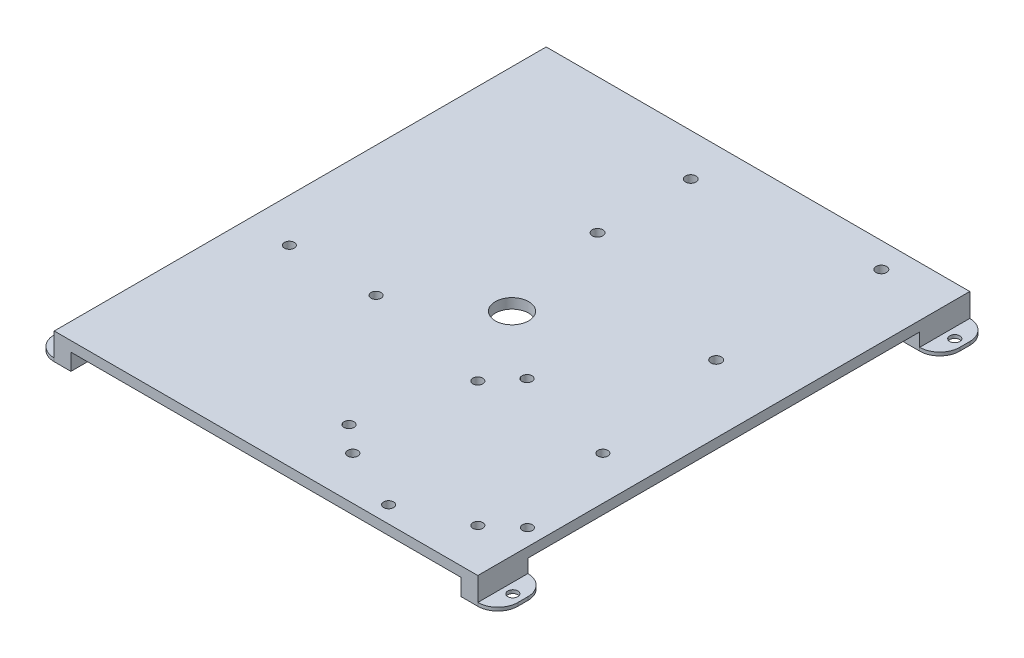
from build123d import *

# Parameters (mm, degrees)
BASE_SKETCH_W              = 127
BASE_SKETCH_H              = 147.5
BASE_SKETCH_R              = 5
BASE_DEPTH                 = 3
LEGS_SKETCH_W              = 5
LEGS_SKETCH_H              = 15
LEGS_DEPTH                 = 5
MOUNT_SKETCH_W             = 15
MOUNT_SKETCH_H             = 1
MOUNT_DEPTH                = 6
DONT_CUT_URSELF_R          = 6
MOUNTING_HOLE_SKETCH_R     = 1.5
MOUNTING_HOLE_1_DEPTH      = 2
MOUNTING_HOLE_2_SKETCH_R   = 1.5
MOUNTING_HOLE_2_DEPTH      = 2
MOUNT_2_SKETCH_W           = 15
MOUNT_2_SKETCH_H           = 1
MOUNT_2_DEPTH              = 6
DONT_CUT_URSELF_2_R        = 6
MOUNTING_HOLE_3_SKETCH_R   = 1.5
MOUNTING_HOLE_3_DEPTH      = 2
MOUNTING_HOLE_4_SKETCH_R   = 1.5
MOUNTING_HOLE_4_DEPTH      = 2
HOLES_FOR_PARTS_REACH      = 10
HOLES_FOR_PARTS_SKETCH_R   = 1.5
HOLES_FOR_PARTS_SKETCH_R_2 = 1.59


with BuildPart() as part:
    # Base Sketch → Base (new body)
    with BuildSketch(Plane(origin=(0, 0, 0), x_dir=(1, 0, 0), z_dir=(0, 1, 0))):
        Rectangle(BASE_SKETCH_W, BASE_SKETCH_H)
        Circle(BASE_SKETCH_R, mode=Mode.SUBTRACT)
    extrude(amount=BASE_DEPTH)

    # Legs Sketch → Legs (add)
    with BuildSketch(Plane.XZ):
        with Locations((-61, -66.25)):
            Rectangle(LEGS_SKETCH_W, LEGS_SKETCH_H)
        with Locations((61, -66.25)):
            Rectangle(LEGS_SKETCH_W, LEGS_SKETCH_H)
        with Locations((-61, 66.25)):
            Rectangle(LEGS_SKETCH_W, LEGS_SKETCH_H)
        with Locations((61, 66.25)):
            Rectangle(LEGS_SKETCH_W, LEGS_SKETCH_H)
    extrude(amount=LEGS_DEPTH)

    # Mount Sketch → Mount (add)
    with BuildSketch(Plane(origin=(63.5, 0, 0), x_dir=(0, 0, -1), z_dir=(1, 0, 0))):
        with Locations((-66.25, -4.5)):
            Rectangle(MOUNT_SKETCH_W, MOUNT_SKETCH_H)
        with Locations((66.25, -4.5)):
            Rectangle(MOUNT_SKETCH_W, MOUNT_SKETCH_H)
    extrude(amount=MOUNT_DEPTH)

    # Dont cut urself
    dont_cut_urself_edges = [part.edges().sort_by_distance(p)[0] for p in [
        (69.5, -4.5, 58.75),
        (69.5, -4.5, 73.75),
        (69.5, -4.5, -73.75),
        (69.5, -4.5, -58.75),
    ]]
    fillet(dont_cut_urself_edges, radius=DONT_CUT_URSELF_R)

    # Mounting Hole Sketch → Mounting Hole 1 (cut, through all)
    with BuildSketch(Plane(origin=(0, -4, 0), x_dir=(1, 0, 0), z_dir=(0, 1, 0))):
        with Locations((66.5, -66.25)):
            Circle(MOUNTING_HOLE_SKETCH_R)
    extrude(amount=-MOUNTING_HOLE_1_DEPTH, mode=Mode.SUBTRACT)

    # Mounting Hole 2 Sketch → Mounting Hole 2 (cut, through all)
    with BuildSketch(Plane(origin=(0, -4, 0), x_dir=(1, 0, 0), z_dir=(0, 1, 0))):
        with Locations((66.5, 66.25)):
            Circle(MOUNTING_HOLE_2_SKETCH_R)
    extrude(amount=-MOUNTING_HOLE_2_DEPTH, mode=Mode.SUBTRACT)

    # Mount 2 Sketch → Mount 2 (add)
    with BuildSketch(Plane.ZY.offset(63.5)):
        with Locations((-66.25, -4.5)):
            Rectangle(MOUNT_2_SKETCH_W, MOUNT_2_SKETCH_H)
        with Locations((66.25, -4.5)):
            Rectangle(MOUNT_2_SKETCH_W, MOUNT_2_SKETCH_H)
    extrude(amount=MOUNT_2_DEPTH)

    # Dont cut urself 2
    dont_cut_urself_2_edges = [part.edges().sort_by_distance(p)[0] for p in [
        (-69.5, -4.5, 73.75),
        (-69.5, -4.5, 58.75),
        (-69.5, -4.5, -58.75),
        (-69.5, -4.5, -73.75),
    ]]
    fillet(dont_cut_urself_2_edges, radius=DONT_CUT_URSELF_2_R)

    # Mounting Hole 3 Sketch → Mounting Hole 3 (cut, through all)
    with BuildSketch(Plane(origin=(0, -4, 0), x_dir=(1, 0, 0), z_dir=(0, 1, 0))):
        with Locations((-66.5, -66.25)):
            Circle(MOUNTING_HOLE_3_SKETCH_R)
    extrude(amount=-MOUNTING_HOLE_3_DEPTH, mode=Mode.SUBTRACT)

    # Mounting Hole 4 Sketch → Mounting Hole 4 (cut, through all)
    with BuildSketch(Plane(origin=(0, -4, 0), x_dir=(1, 0, 0), z_dir=(0, 1, 0))):
        with Locations((-66.5, 66.25)):
            Circle(MOUNTING_HOLE_4_SKETCH_R)
    extrude(amount=-MOUNTING_HOLE_4_DEPTH, mode=Mode.SUBTRACT)

    # Holes for Parts Sketch → Holes for Parts (cut, up to next)
    with BuildSketch(Plane(origin=(0, 3, 0), x_dir=(1, 0, 0), z_dir=(0, 1, 0)), mode=Mode.PRIVATE) as holes_for_parts_sk1:
        with Locations((31.75, -68.75)):
            Circle(HOLES_FOR_PARTS_SKETCH_R)
    holes_for_parts_tool1 = extrude(holes_for_parts_sk1.sketch, amount=-HOLES_FOR_PARTS_REACH, mode=Mode.PRIVATE) & part.part
    add(holes_for_parts_tool1.solids().sort_by_distance((31.75, 3, 68.75))[0], mode=Mode.SUBTRACT)
    # Holes for Parts Sketch → Holes for Parts (cut, up to next)
    with BuildSketch(Plane(origin=(0, 3, 0), x_dir=(1, 0, 0), z_dir=(0, 1, 0)), mode=Mode.PRIVATE) as holes_for_parts_sk2:
        with Locations((58.5, -53.875)):
            Circle(HOLES_FOR_PARTS_SKETCH_R)
    holes_for_parts_tool2 = extrude(holes_for_parts_sk2.sketch, amount=-HOLES_FOR_PARTS_REACH, mode=Mode.PRIVATE) & part.part
    add(holes_for_parts_tool2.solids().sort_by_distance((58.5, 3, 53.875))[0], mode=Mode.SUBTRACT)
    # Holes for Parts Sketch → Holes for Parts (cut, up to next)
    with BuildSketch(Plane(origin=(0, 3, 0), x_dir=(1, 0, 0), z_dir=(0, 1, 0)), mode=Mode.PRIVATE) as holes_for_parts_sk3:
        with Locations((5, -53.875)):
            Circle(HOLES_FOR_PARTS_SKETCH_R)
    holes_for_parts_tool3 = extrude(holes_for_parts_sk3.sketch, amount=-HOLES_FOR_PARTS_REACH, mode=Mode.PRIVATE) & part.part
    add(holes_for_parts_tool3.solids().sort_by_distance((5, 3, 53.875))[0], mode=Mode.SUBTRACT)
    # Holes for Parts Sketch → Holes for Parts (cut, up to next)
    with BuildSketch(Plane(origin=(0, 3, 0), x_dir=(1, 0, 0), z_dir=(0, 1, 0)), mode=Mode.PRIVATE) as holes_for_parts_sk4:
        with Locations((19.75, -15.25)):
            Circle(HOLES_FOR_PARTS_SKETCH_R)
    holes_for_parts_tool4 = extrude(holes_for_parts_sk4.sketch, amount=-HOLES_FOR_PARTS_REACH, mode=Mode.PRIVATE) & part.part
    add(holes_for_parts_tool4.solids().sort_by_distance((19.75, 3, 15.25))[0], mode=Mode.SUBTRACT)
    # Holes for Parts Sketch → Holes for Parts (cut, up to next)
    with BuildSketch(Plane(origin=(0, 3, 0), x_dir=(1, 0, 0), z_dir=(0, 1, 0)), mode=Mode.PRIVATE) as holes_for_parts_sk5:
        with Locations((-50.5, -16.25)):
            Circle(HOLES_FOR_PARTS_SKETCH_R)
    holes_for_parts_tool5 = extrude(holes_for_parts_sk5.sketch, amount=-HOLES_FOR_PARTS_REACH, mode=Mode.PRIVATE) & part.part
    add(holes_for_parts_tool5.solids().sort_by_distance((-50.5, 3, 16.25))[0], mode=Mode.SUBTRACT)
    # Holes for Parts Sketch → Holes for Parts (cut, up to next)
    with BuildSketch(Plane(origin=(0, 3, 0), x_dir=(1, 0, 0), z_dir=(0, 1, 0)), mode=Mode.PRIVATE) as holes_for_parts_sk6:
        with Locations((-24.5, -16.25)):
            Circle(HOLES_FOR_PARTS_SKETCH_R)
    holes_for_parts_tool6 = extrude(holes_for_parts_sk6.sketch, amount=-HOLES_FOR_PARTS_REACH, mode=Mode.PRIVATE) & part.part
    add(holes_for_parts_tool6.solids().sort_by_distance((-24.5, 3, 16.25))[0], mode=Mode.SUBTRACT)
    # Holes for Parts Sketch → Holes for Parts (cut, up to next)
    with BuildSketch(Plane(origin=(0, 3, 0), x_dir=(1, 0, 0), z_dir=(0, 1, 0)), mode=Mode.PRIVATE) as holes_for_parts_sk7:
        with Locations((-7.54, 33.19)):
            Circle(HOLES_FOR_PARTS_SKETCH_R_2)
    holes_for_parts_tool7 = extrude(holes_for_parts_sk7.sketch, amount=-HOLES_FOR_PARTS_REACH, mode=Mode.PRIVATE) & part.part
    add(holes_for_parts_tool7.solids().sort_by_distance((-7.54, 3, -33.19))[0], mode=Mode.SUBTRACT)
    # Holes for Parts Sketch → Holes for Parts (cut, up to next)
    with BuildSketch(Plane(origin=(0, 3, 0), x_dir=(1, 0, 0), z_dir=(0, 1, 0)), mode=Mode.PRIVATE) as holes_for_parts_sk8:
        with Locations((-7.54, 61.13)):
            Circle(HOLES_FOR_PARTS_SKETCH_R_2)
    holes_for_parts_tool8 = extrude(holes_for_parts_sk8.sketch, amount=-HOLES_FOR_PARTS_REACH, mode=Mode.PRIVATE) & part.part
    add(holes_for_parts_tool8.solids().sort_by_distance((-7.54, 3, -61.13))[0], mode=Mode.SUBTRACT)
    # Holes for Parts Sketch → Holes for Parts (cut, up to next)
    with BuildSketch(Plane(origin=(0, 3, 0), x_dir=(1, 0, 0), z_dir=(0, 1, 0)), mode=Mode.PRIVATE) as holes_for_parts_sk9:
        with Locations((44.53, 66.21)):
            Circle(HOLES_FOR_PARTS_SKETCH_R_2)
    holes_for_parts_tool9 = extrude(holes_for_parts_sk9.sketch, amount=-HOLES_FOR_PARTS_REACH, mode=Mode.PRIVATE) & part.part
    add(holes_for_parts_tool9.solids().sort_by_distance((44.53, 3, -66.21))[0], mode=Mode.SUBTRACT)
    # Holes for Parts Sketch → Holes for Parts (cut, up to next)
    with BuildSketch(Plane(origin=(0, 3, 0), x_dir=(1, 0, 0), z_dir=(0, 1, 0)), mode=Mode.PRIVATE) as holes_for_parts_sk10:
        with Locations((43.26, 17.95)):
            Circle(HOLES_FOR_PARTS_SKETCH_R_2)
    holes_for_parts_tool10 = extrude(holes_for_parts_sk10.sketch, amount=-HOLES_FOR_PARTS_REACH, mode=Mode.PRIVATE) & part.part
    add(holes_for_parts_tool10.solids().sort_by_distance((43.26, 3, -17.95))[0], mode=Mode.SUBTRACT)
    # Holes for Parts Sketch → Holes for Parts (cut, up to next)
    with BuildSketch(Plane(origin=(0, 3, 0), x_dir=(1, 0, 0), z_dir=(0, 1, 0)), mode=Mode.PRIVATE) as holes_for_parts_sk11:
        with Locations((50.5, -60.75)):
            Circle(HOLES_FOR_PARTS_SKETCH_R)
    holes_for_parts_tool11 = extrude(holes_for_parts_sk11.sketch, amount=-HOLES_FOR_PARTS_REACH, mode=Mode.PRIVATE) & part.part
    add(holes_for_parts_tool11.solids().sort_by_distance((50.5, 3, 60.75))[0], mode=Mode.SUBTRACT)
    # Holes for Parts Sketch → Holes for Parts (cut, up to next)
    with BuildSketch(Plane(origin=(0, 3, 0), x_dir=(1, 0, 0), z_dir=(0, 1, 0)), mode=Mode.PRIVATE) as holes_for_parts_sk12:
        with Locations((13, -60.75)):
            Circle(HOLES_FOR_PARTS_SKETCH_R)
    holes_for_parts_tool12 = extrude(holes_for_parts_sk12.sketch, amount=-HOLES_FOR_PARTS_REACH, mode=Mode.PRIVATE) & part.part
    add(holes_for_parts_tool12.solids().sort_by_distance((13, 3, 60.75))[0], mode=Mode.SUBTRACT)
    # Holes for Parts Sketch → Holes for Parts (cut, up to next)
    with BuildSketch(Plane(origin=(0, 3, 0), x_dir=(1, 0, 0), z_dir=(0, 1, 0)), mode=Mode.PRIVATE) as holes_for_parts_sk13:
        with Locations((13, -23.25)):
            Circle(HOLES_FOR_PARTS_SKETCH_R)
    holes_for_parts_tool13 = extrude(holes_for_parts_sk13.sketch, amount=-HOLES_FOR_PARTS_REACH, mode=Mode.PRIVATE) & part.part
    add(holes_for_parts_tool13.solids().sort_by_distance((13, 3, 23.25))[0], mode=Mode.SUBTRACT)
    # Holes for Parts Sketch → Holes for Parts (cut, up to next)
    with BuildSketch(Plane(origin=(0, 3, 0), x_dir=(1, 0, 0), z_dir=(0, 1, 0)), mode=Mode.PRIVATE) as holes_for_parts_sk14:
        with Locations((50.5, -23.25)):
            Circle(HOLES_FOR_PARTS_SKETCH_R)
    holes_for_parts_tool14 = extrude(holes_for_parts_sk14.sketch, amount=-HOLES_FOR_PARTS_REACH, mode=Mode.PRIVATE) & part.part
    add(holes_for_parts_tool14.solids().sort_by_distance((50.5, 3, 23.25))[0], mode=Mode.SUBTRACT)


solid = part.part
